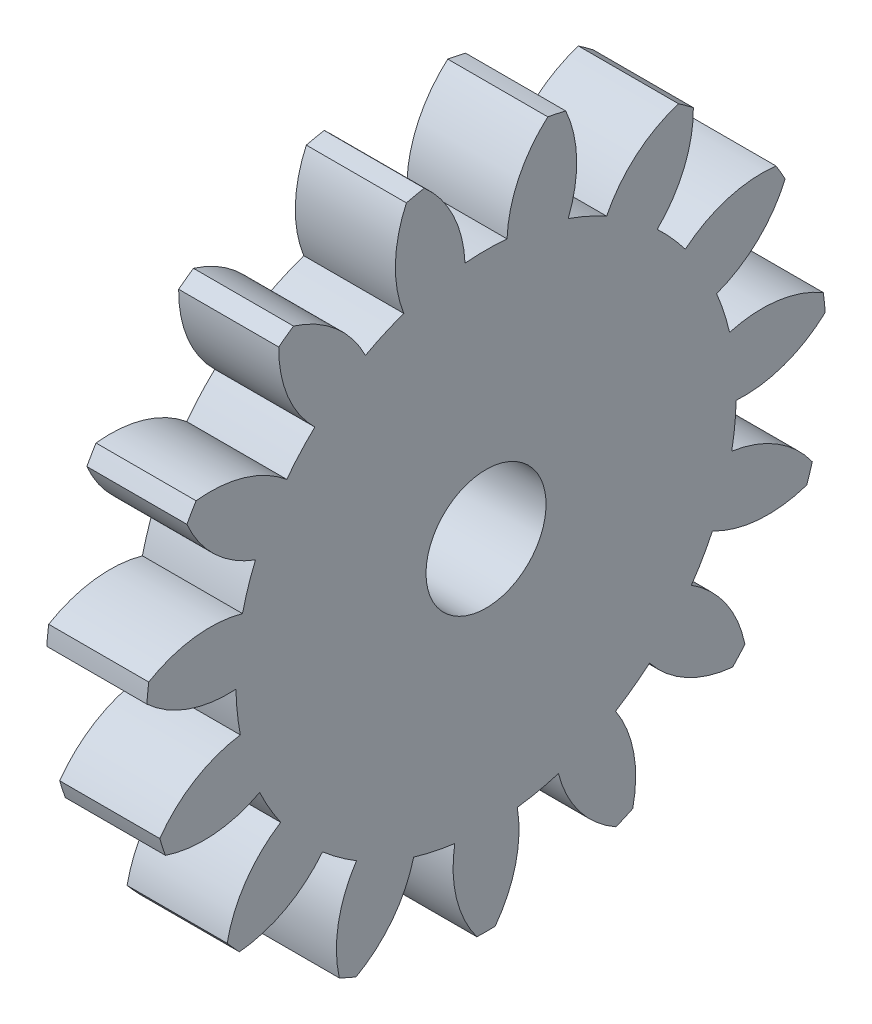
from build123d import *

# Parameters (mm, degrees)
BASPROSKE_W     = 5
BASPROSKE_H     = 17
TOOTHCUT_DEPTH  = 25.556058316
TEETHCUTS_COUNT = 15
TEETHCUTS_ANGLE = 336
BORSKE_R        = 3
BORE_DEPTH      = 50.0000508


with BuildPart() as part:
    # BasProSke → Base-Revolve (revolve)
    with BuildSketch(Plane(origin=(0, 0, 0), x_dir=(1, 0, 0), z_dir=(0, 1, 0)), mode=Mode.PRIVATE) as base_revolve_sk:
        with Locations((2.5, 8.5)):
            Rectangle(BASPROSKE_W, BASPROSKE_H)
    revolve(base_revolve_sk.sketch.rotate(Axis((-10, 0, 0), (1, 0, 0)), 180), axis=Axis((-10, 0, 0), (1, 0, 0)))

    # TooCutSke → ToothCut (cut, through all)
    with BuildSketch(Plane(origin=(0, 0, 0), x_dir=(0, 0, -1), z_dir=(1, 0, 0))):
        with BuildLine():
            ThreePointArc((1.050056448, 12.454813626), (0, 12.499), (-1.050056448, 12.454813626))
            ThreePointArc((-1.050056448, 12.454813626), (-1.638118106, 14.809604533), (-3.110934279, 16.73876737))
            ThreePointArc((-3.110934279, 16.73876737), (0, 17.0254), (3.110934279, 16.73876737))
            ThreePointArc((3.110934279, 16.73876737), (1.638118106, 14.809604533), (1.050056448, 12.454813626))
        make_face()
    toothcut = extrude(amount=TOOTHCUT_DEPTH, mode=Mode.SUBTRACT)

    # TeethCuts: ToothCut ×15 about axis
    teethcuts_axis = Axis((-10, 0, 0), (1, 0, 0))
    for i in range(1, TEETHCUTS_COUNT):
        add(toothcut.rotate(teethcuts_axis, i * TEETHCUTS_ANGLE / (TEETHCUTS_COUNT - 1)), mode=Mode.SUBTRACT)

    # BorSke → Bore (cut, symmetric)
    with BuildSketch(Plane(origin=(0, 0, 0), x_dir=(0, 0, -1), z_dir=(1, 0, 0))):
        with Locations(Location((0, 0, 0), (0, 0, 180))):
            Circle(BORSKE_R)
    extrude(amount=BORE_DEPTH, both=True, mode=Mode.SUBTRACT)


solid = part.part
